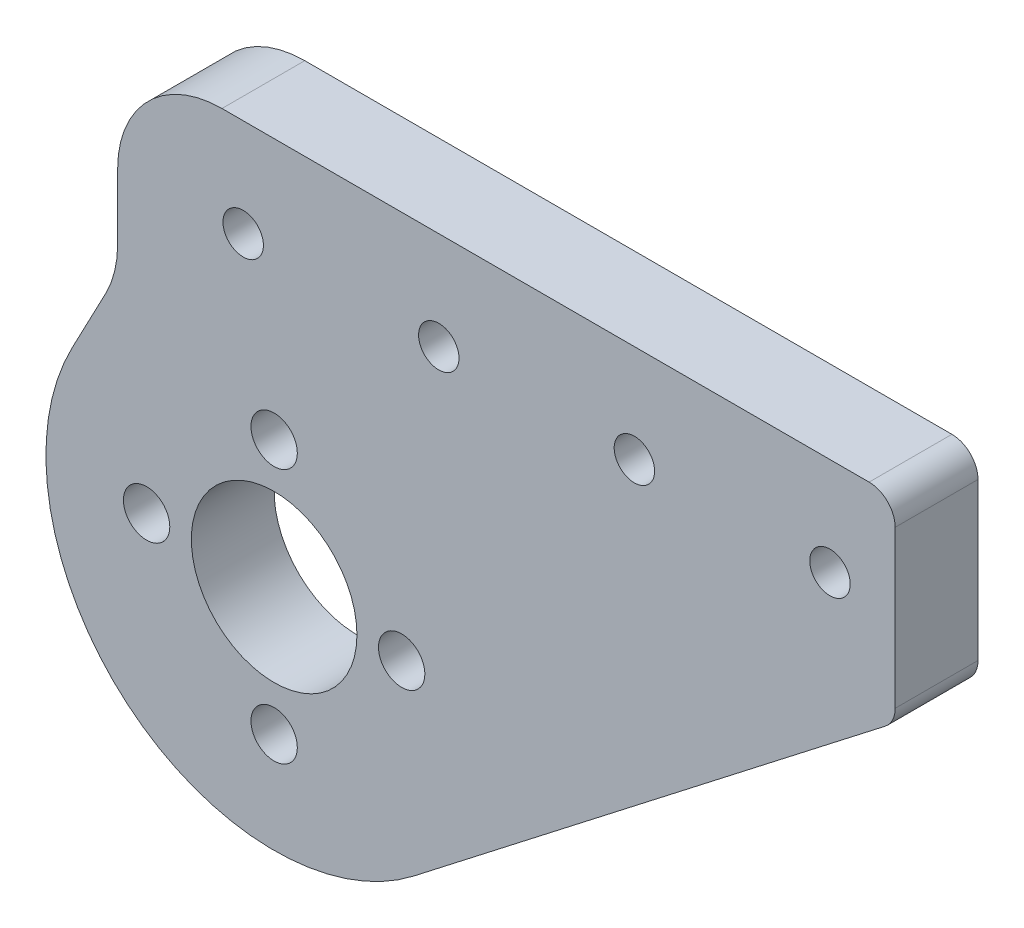
from build123d import *

# Parameters (mm, degrees)
SKETCH1_R           = 1.778
SKETCH1_R_2         = 1.55
SKETCH1_R_3         = 6.35
BOSS_EXTRUDE1_DEPTH = 6.35
FILLET2_R           = 2
FILLET4_R           = 8


with BuildPart() as part:
    # Sketch1 → Boss-Extrude1 (new body)
    with BuildSketch(Plane.XY):
        with BuildLine():
            Line((47.626117997, 29.779), (-12, 29.779))
            Line((-12, 29.779), (-12, 14.779))
            Line((-12, 14.779), (-15.488554272, 8.145838605))
            ThreePointArc((-15.488554272, 8.145838605), (-11.243708258, -13.410034474), (10.72211713, -13.830625591))
            Line((10.72211713, -13.830625591), (47.626117997, 14.779))
            Line((47.626117997, 14.779), (47.626117997, 29.779))
        make_face()
        with Locations((-9.779, 0)):
            Circle(SKETCH1_R, mode=Mode.SUBTRACT)
        with Locations((0, -9.779)):
            Circle(SKETCH1_R, mode=Mode.SUBTRACT)
        with Locations((0, 9.779)):
            Circle(SKETCH1_R, mode=Mode.SUBTRACT)
        with Locations((9.779, 0)):
            Circle(SKETCH1_R, mode=Mode.SUBTRACT)
        with Locations((-2.373882003, 22.279)):
            Circle(SKETCH1_R_2, mode=Mode.SUBTRACT)
        with Locations((12.626117997, 22.279)):
            Circle(SKETCH1_R_2, mode=Mode.SUBTRACT)
        with Locations((27.626117997, 22.279)):
            Circle(SKETCH1_R_2, mode=Mode.SUBTRACT)
        with Locations((42.626117997, 22.279)):
            Circle(SKETCH1_R_2, mode=Mode.SUBTRACT)
        Circle(SKETCH1_R_3, mode=Mode.SUBTRACT)
    extrude(amount=BOSS_EXTRUDE1_DEPTH)

    # Fillet2
    fillet2_edges = [part.edges().sort_by_distance(p)[0] for p in [
        (47.626117997, 29.779, 3.175),
        (47.626117997, 14.779, 3.175),
    ]]
    fillet(fillet2_edges, radius=FILLET2_R)

    # Fillet4
    fillet4_edges = [part.edges().sort_by_distance(p)[0] for p in [
        (-12, 14.779, 3.175),
        (-12, 29.779, 3.175),
    ]]
    fillet(fillet4_edges, radius=FILLET4_R)


solid = part.part
